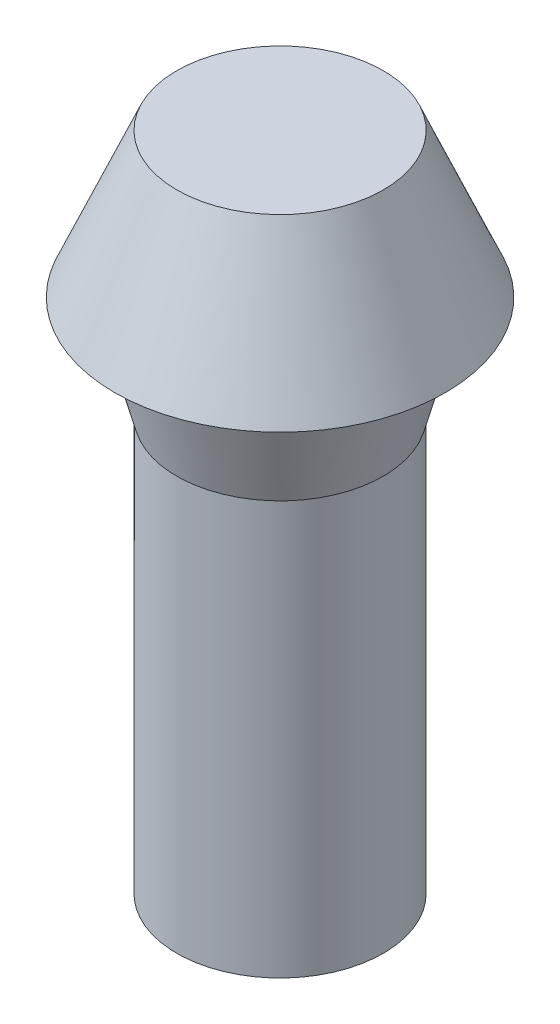
from build123d import *

# Parameters (mm, degrees)
SKETCH3_R           = 5
SKETCH1_R           = 8
SKETCH4_R           = 5
BOSS_EXTRUDE1_DEPTH = 5
BOSS_EXTRUDE1_TAPER = -15
SKETCH5_R           = 5
BOSS_EXTRUDE2_DEPTH = 20


with BuildPart() as part:
    # Sketch3 → Loft1 section 0
    with BuildSketch(Plane(origin=(0, 7, 0), x_dir=(1, 0, 0), z_dir=(0, 1, 0))):
        Circle(SKETCH3_R)
    # Sketch1 → Loft1 section 1
    with BuildSketch(Plane(origin=(0, 0, 0), x_dir=(1, 0, 0), z_dir=(0, 1, 0))):
        Circle(SKETCH1_R)
    loft()

    # Sketch4 → Boss-Extrude1 (add)
    with BuildSketch(Plane(origin=(0, -5, 0), x_dir=(-1, 0, 0), z_dir=(0, -1, 0))):
        Circle(SKETCH4_R)
    extrude(amount=-BOSS_EXTRUDE1_DEPTH, taper=BOSS_EXTRUDE1_TAPER)

    # Sketch5 → Boss-Extrude2 (add)
    with BuildSketch(Plane(origin=(0, -5, 0), x_dir=(-1, 0, 0), z_dir=(0, -1, 0))):
        Circle(SKETCH5_R)
    extrude(amount=BOSS_EXTRUDE2_DEPTH)


solid = part.part
